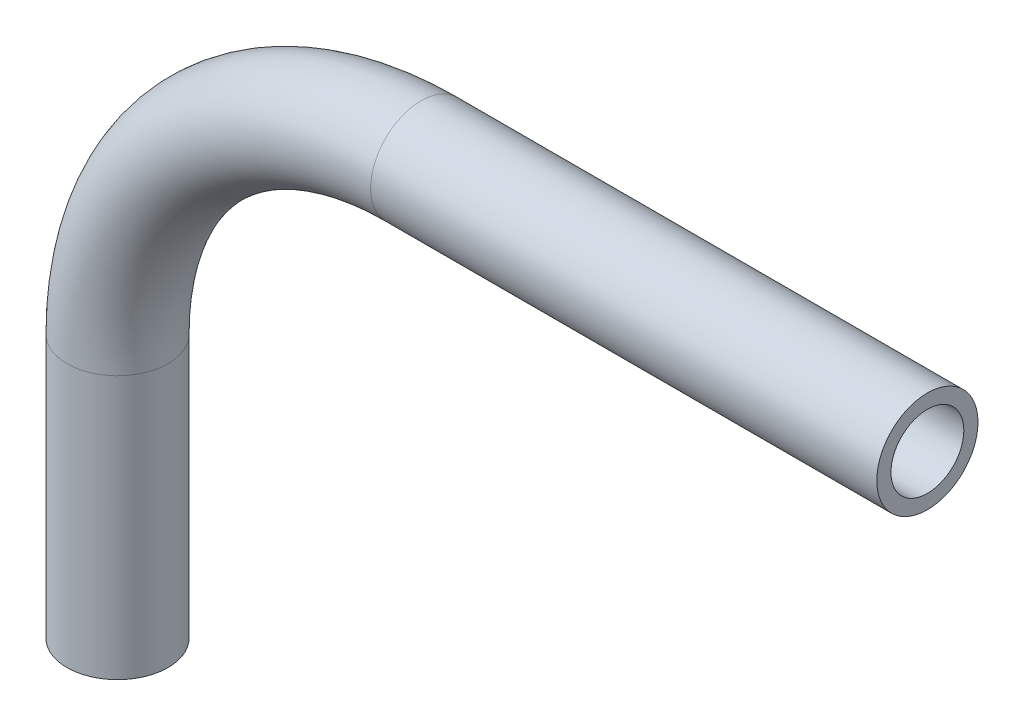
from build123d import *

# Parameters (mm, degrees)
SKETCH2_R   = 3.175
SKETCH2_R_2 = 2.286


with BuildPart() as part:
    # Sweep1: sweep along a path in Sketch1
    with BuildLine(Plane.XY) as sweep1_path:
        Line((0, -18.032317881), (0, -1.522317881))
        ThreePointArc((0, -1.522317881), (5.579615818, 11.948066301), (19.05, 17.527682119))
        Line((19.05, 17.527682119), (50.8, 17.527682119))
    # Sketch2 → Sweep1 (sweep)
    with BuildSketch(Plane(origin=(50.8, 17.527682119, 0), x_dir=(0, 0, -1), z_dir=(1, 0, 0))):
        Circle(SKETCH2_R)
        Circle(SKETCH2_R_2, mode=Mode.SUBTRACT)
    sweep(path=sweep1_path.line)


solid = part.part
